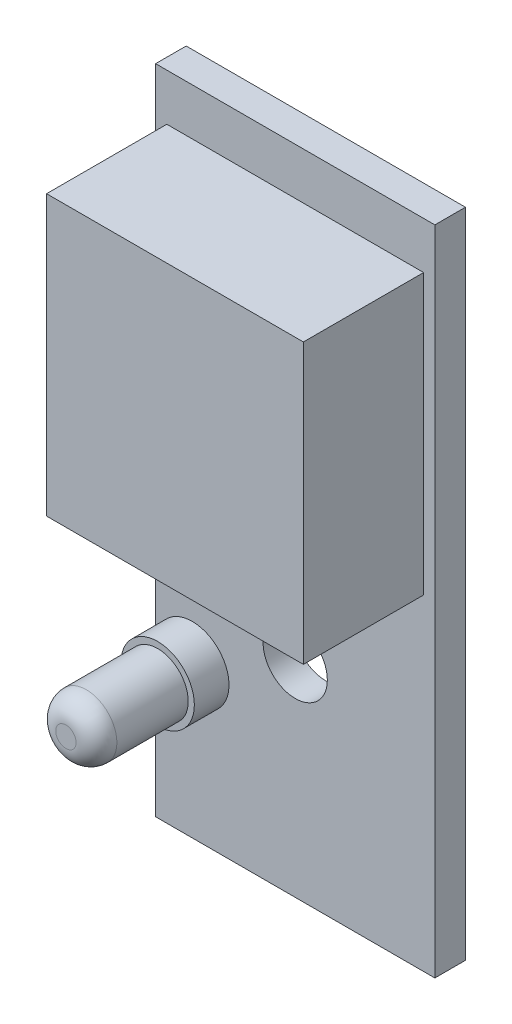
from build123d import *

# Parameters (mm, degrees)
SKETCH1_W           = 13.7
SKETCH1_H           = 32
BOSS_EXTRUDE1_DEPTH = 1.5
SKETCH2_W           = 12.6
SKETCH2_H           = 13.7
BOSS_EXTRUDE2_DEPTH = 5.9
SKETCH3_R           = 1.8
BOSS_EXTRUDE3_DEPTH = 1.7
SKETCH6_R           = 1.5
BOSS_EXTRUDE4_DEPTH = 4.5
FILLET1_R           = 1
SKETCH7_R           = 1.575
CUT_EXTRUDE1_DEPTH  = 2.5


with BuildPart() as part:
    # Sketch1 → Boss-Extrude1 (new body)
    with BuildSketch(Plane.XY):
        Rectangle(SKETCH1_W, SKETCH1_H)
    extrude(amount=BOSS_EXTRUDE1_DEPTH)

    # Sketch2 → Boss-Extrude2 (add)
    with BuildSketch(Plane.XY.offset(1.5)):
        with Locations((0, 6.85)):
            Rectangle(SKETCH2_W, SKETCH2_H)
    extrude(amount=BOSS_EXTRUDE2_DEPTH)

    # Sketch3 → Boss-Extrude3 (add)
    with BuildSketch(Plane.XY.offset(1.5)):
        with Locations((-5.05, -8.6)):
            Circle(SKETCH3_R)
    extrude(amount=BOSS_EXTRUDE3_DEPTH)

    # Sketch6 → Boss-Extrude4 (add)
    with BuildSketch(Plane.XY.offset(3.2)):
        with Locations((-5.05, -8.6)):
            Circle(SKETCH6_R)
    extrude(amount=BOSS_EXTRUDE4_DEPTH)

    # Fillet1
    fillet1_edges = [part.edges().sort_by_distance(p)[0] for p in [
        (-6.55, -8.6, 7.7),
    ]]
    fillet(fillet1_edges, radius=FILLET1_R)

    # Sketch7 → Cut-Extrude1 (cut, through all)
    with BuildSketch(Plane.XY.offset(1.5)):
        with Locations((0, -5.975)):
            Circle(SKETCH7_R)
    extrude(amount=-CUT_EXTRUDE1_DEPTH, mode=Mode.SUBTRACT)


solid = part.part
